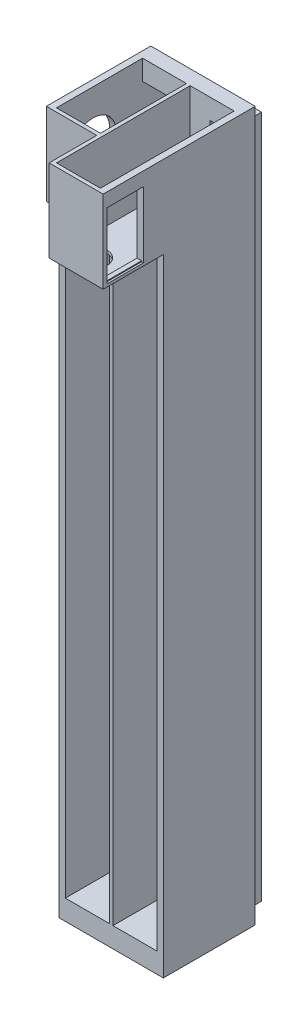
from build123d import *

# Parameters (mm, degrees)
SZKIC1_W                     = 53
SZKIC1_H                     = 374
SZKIC1_W_2                   = 24
SZKIC1_H_2                   = 365
DODANIE_WYCI_GNI_CIE2_DEPTH  = 12
SZKIC2_W                     = 12
SZKIC2_H                     = 3.5
WYTNIJ_WYCI_GNI_CIE1_DEPTH   = 2
SZKIC3_W                     = 53
SZKIC3_H                     = 374
DODANIE_WYCI_GNI_CIE3_DEPTH  = 2
SZKIC4_W                     = 13.3
SZKIC4_H                     = 30.500081729
SZKIC4_W_2                   = 9.4
SZKIC4_H_2                   = 64.96
WYTNIJ_WYCI_GNI_CIE2_DEPTH   = 2
SZKIC5_W                     = 2
SZKIC5_H                     = 374
DODANIE_WYCI_GNI_CIE4_DEPTH  = 43
DODANIE_WYCI_GNI_CIE5_DEPTH  = 41.5
SZKIC7_W                     = 25.5
SZKIC7_H                     = 38.500081729
DODANIE_WYCI_GNI_CIE6_DEPTH  = 1.5
DODANIE_WYCI_GNI_CIE7_DEPTH  = 43
DODANIE_WYCI_GNI_CIE8_DEPTH  = 43
SZKIC15_W                    = 57
SZKIC15_H                    = 374
DODANIE_WYCI_GNI_CIE10_DEPTH = 1
SZKIC16_W                    = 57
SZKIC16_H                    = 374
DODANIE_WYCI_GNI_CIE11_DEPTH = 1
SZKIC17_W                    = 55
SZKIC17_H                    = 57
SZKIC17_W_2                  = 24
SZKIC17_H_2                  = 41.5
DODANIE_WYCI_GNI_CIE12_DEPTH = 1
SZKIC18_W                    = 55
SZKIC18_H                    = 57
DODANIE_WYCI_GNI_CIE13_DEPTH = 1
SZKIC19_W                    = 55
SZKIC19_H                    = 376
SZKIC19_W_2                  = 52
SZKIC19_H_2                  = 373
WYTNIJ_WYCI_GNI_CIE7_DEPTH   = 6
SZKIC23_W                    = 24
SZKIC23_H                    = 38.000081729
WYTNIJ_WYCI_GNI_CIE11_DEPTH  = 10
DODANIE_WYCI_GNI_CIE14_DEPTH = 32
SZKIC25_W                    = 24
SZKIC25_H                    = 2
DODANIE_WYCI_GNI_CIE15_DEPTH = 38
SZKIC27_R                    = 7
WYTNIJ_WYCI_GNI_CIE12_DEPTH  = 10
SZKIC29_W                    = 20
SZKIC29_H                    = 35.5
WYTNIJ_WYCI_GNI_CIE13_DEPTH  = 3
DODANIE_WYCI_GNI_CIE16_DEPTH = 6
SZKIC31_W                    = 24
SZKIC31_H                    = 2
DODANIE_WYCI_GNI_CIE17_DEPTH = 38
SZKIC32_R                    = 12.5
WYTNIJ_WYCI_GNI_CIE14_DEPTH  = 3
SZKIC33_W                    = 24
SZKIC33_H                    = 73
SZKIC33_H_2                  = 47
DODANIE_WYCI_GNI_CIE18_DEPTH = 5.5
SZKIC34_W                    = 55
SZKIC34_H                    = 51
DODANIE_WYCI_GNI_CIE19_DEPTH = 5.5
SZKIC35_W                    = 20
SZKIC35_H                    = 36
DODANIE_WYCI_GNI_CIE20_DEPTH = 1
SZKIC36_R                    = 12.5
DODANIE_WYCI_GNI_CIE21_DEPTH = 1
SZKIC37_W                    = 57
SZKIC37_H                    = 341.999918271
WYTNIJ_WYCI_GNI_CIE15_DEPTH  = 0.85


with BuildPart() as part:
    # Szkic1 → Dodanie-wyciągnięcie2 (new body)
    with BuildSketch(Plane.XY):
        with Locations((-65.426891924, -133.239080048)):
            Rectangle(SZKIC1_W, SZKIC1_H)
        with Locations((-78.426891924, -133.239080048)):
            Rectangle(SZKIC1_W_2, SZKIC1_H_2, mode=Mode.SUBTRACT)
        with Locations((-52.426891924, -133.239080048)):
            Rectangle(SZKIC1_W_2, SZKIC1_H_2, mode=Mode.SUBTRACT)
    extrude(amount=DODANIE_WYCI_GNI_CIE2_DEPTH)

    # Szkic2 → Wytnij-wyciągnięcie1 (cut)
    with BuildSketch(Plane.ZY.offset(66.426891924)):
        with Locations((6, 47.510919952)):
            Rectangle(SZKIC2_W, SZKIC2_H)
    extrude(amount=-WYTNIJ_WYCI_GNI_CIE1_DEPTH, mode=Mode.SUBTRACT)

    # Szkic3 → Dodanie-wyciągnięcie3 (add)
    with BuildSketch(Plane.XY.offset(12)):
        with Locations((-65.426891924, -133.239080048)):
            Rectangle(SZKIC3_W, SZKIC3_H)
    extrude(amount=DODANIE_WYCI_GNI_CIE3_DEPTH)

    # Szkic4 → Wytnij-wyciągnięcie2 (cut)
    with BuildSketch(Plane.XY.offset(14)):
        Polygon((-46.926891924, -11.039080048), (-56.326891924, -11.039080048), (-56.326891924, -35.399080048), (-56.326891924, -40.479080048), (-46.926891924, -40.479080048), (-46.926891924, -35.399080048), align=None)
        with Locations((-47.076891924, 34.010879088)):
            Rectangle(SZKIC4_W, SZKIC4_H)
        with Locations((-83.776891924, 34.010879088)):
            Rectangle(SZKIC4_W, SZKIC4_H)
        Polygon((-74.526891924, -35.399080048), (-74.526891924, -40.479080048), (-83.926891924, -40.479080048), (-83.926891924, -35.399080048), (-83.926891924, -11.039080048), (-74.526891924, -11.039080048), align=None)
        with Locations((-51.626891924, -133.719080048)):
            Rectangle(SZKIC4_W_2, SZKIC4_H_2)
        with Locations((-79.226891924, -133.719080048)):
            Rectangle(SZKIC4_W_2, SZKIC4_H_2)
    extrude(amount=-WYTNIJ_WYCI_GNI_CIE2_DEPTH, mode=Mode.SUBTRACT)

    # Szkic5 → Dodanie-wyciągnięcie4 (add)
    with BuildSketch(Plane.XY.offset(14)):
        with Locations((-65.426891924, -133.239080048)):
            Rectangle(SZKIC5_W, SZKIC5_H)
    extrude(amount=DODANIE_WYCI_GNI_CIE4_DEPTH)

    # Szkic6 → Dodanie-wyciągnięcie5 (add)
    with BuildSketch(Plane.XY.offset(14)):
        Polygon((-64.426891924, 16.760838223), (-40.426891924, 16.760838223), (-40.426891924, 53.760919952), (-38.926891924, 53.760919952), (-38.926891924, 15.260838223), (-64.426891924, 15.260838223), align=None)
        Polygon((-90.426891924, 53.760919952), (-91.926891924, 53.760919952), (-91.926891924, 15.260838223), (-66.426891924, 15.260838223), (-66.426891924, 16.760838223), (-90.426891924, 16.760838223), align=None)
    extrude(amount=DODANIE_WYCI_GNI_CIE5_DEPTH)

    # Szkic7 → Dodanie-wyciągnięcie6 (add)
    with BuildSketch(Plane.XY.offset(55.5)):
        with Locations((-51.676891924, 34.510879088)):
            Rectangle(SZKIC7_W, SZKIC7_H)
        with Locations((-79.176891924, 34.510879088)):
            Rectangle(SZKIC7_W, SZKIC7_H)
    extrude(amount=DODANIE_WYCI_GNI_CIE6_DEPTH)

    # Szkic10 → Dodanie-wyciągnięcie7 (add)
    with BuildSketch(Plane.XY.offset(14)):
        Polygon((-91.926891924, 15.260838223), (-91.926891924, -320.239080048), (-66.426891924, -320.239080048), (-66.426891924, -315.739080048), (-90.426891924, -315.739080048), (-90.426891924, 15.260838223), align=None)
    extrude(amount=DODANIE_WYCI_GNI_CIE7_DEPTH)

    # Szkic11 → Dodanie-wyciągnięcie8 (add)
    with BuildSketch(Plane.XY.offset(14)):
        Polygon((-38.926891924, 15.260838223), (-38.926891924, -320.239080048), (-64.426891924, -320.239080048), (-64.426891924, -315.739080048), (-40.426891924, -315.739080048), (-40.426891924, 15.260838223), align=None)
    extrude(amount=DODANIE_WYCI_GNI_CIE8_DEPTH)

    # Szkic15 → Dodanie-wyciągnięcie10 (add)
    with BuildSketch(Plane.ZY.offset(91.926891924)):
        with Locations((28.5, -133.239080048)):
            Rectangle(SZKIC15_W, SZKIC15_H)
    extrude(amount=DODANIE_WYCI_GNI_CIE10_DEPTH)

    # Szkic16 → Dodanie-wyciągnięcie11 (add)
    with BuildSketch(Plane(origin=(-38.926891924, 0, 0), x_dir=(0, 0, -1), z_dir=(1, 0, 0))):
        with Locations((-28.5, -133.239080048)):
            Rectangle(SZKIC16_W, SZKIC16_H)
    extrude(amount=DODANIE_WYCI_GNI_CIE11_DEPTH)

    # Szkic17 → Dodanie-wyciągnięcie12 (add)
    with BuildSketch(Plane(origin=(0, 53.760919952, 0), x_dir=(1, 0, 0), z_dir=(0, 1, 0))):
        with Locations((-65.426891924, -28.5)):
            Rectangle(SZKIC17_W, SZKIC17_H)
        with Locations((-52.426891924, -34.75)):
            Rectangle(SZKIC17_W_2, SZKIC17_H_2, mode=Mode.SUBTRACT)
        with Locations((-78.426891924, -34.75)):
            Rectangle(SZKIC17_W_2, SZKIC17_H_2, mode=Mode.SUBTRACT)
    extrude(amount=DODANIE_WYCI_GNI_CIE12_DEPTH)

    # Szkic18 → Dodanie-wyciągnięcie13 (add)
    with BuildSketch(Plane.XZ.offset(320.239080048)):
        with Locations((-65.426891924, 28.5)):
            Rectangle(SZKIC18_W, SZKIC18_H)
    extrude(amount=DODANIE_WYCI_GNI_CIE13_DEPTH)

    # Szkic19 → Wytnij-wyciągnięcie7 (cut)
    with BuildSketch(Plane(origin=(0, 0, 0), x_dir=(-1, 0, 0), z_dir=(0, 0, -1))):
        with Locations((65.426891924, -133.239080048)):
            Rectangle(SZKIC19_W, SZKIC19_H)
        with Locations((65.426891924, -133.239080048)):
            Rectangle(SZKIC19_W_2, SZKIC19_H_2, mode=Mode.SUBTRACT)
    extrude(amount=-WYTNIJ_WYCI_GNI_CIE7_DEPTH, mode=Mode.SUBTRACT)

    # Szkic23 → Wytnij-wyciągnięcie11 (cut)
    with BuildSketch(Plane.XY.offset(57)):
        with Locations((-52.426891924, 35.760879088)):
            Rectangle(SZKIC23_W, SZKIC23_H)
        with Locations((-78.426891924, 35.760879088)):
            Rectangle(SZKIC23_W, SZKIC23_H)
    extrude(amount=-WYTNIJ_WYCI_GNI_CIE11_DEPTH, mode=Mode.SUBTRACT)

    # Szkic24 → Dodanie-wyciągnięcie14 (add)
    with BuildSketch(Plane.XY.offset(57)):
        Polygon((-40.426891924, 54.760919952), (-37.926891924, 54.760919952), (-37.926891924, 15.260838223), (-66.426891924, 15.260838223), (-66.426891924, 16.760838223), (-66.426891924, 54.760919952), (-64.426891924, 54.760919952), (-64.426891924, 16.760838223), (-40.426891924, 16.760838223), align=None)
    extrude(amount=DODANIE_WYCI_GNI_CIE14_DEPTH)

    # Szkic25 → Dodanie-wyciągnięcie15 (add)
    with BuildSketch(Plane(origin=(0, 16.760838223, 0), x_dir=(1, 0, 0), z_dir=(0, 1, 0))):
        with Locations((-52.426891924, -88)):
            Rectangle(SZKIC25_W, SZKIC25_H)
    extrude(amount=DODANIE_WYCI_GNI_CIE15_DEPTH)

    # Szkic27 → Wytnij-wyciągnięcie12 (cut)
    with BuildSketch(Plane.XZ.offset(-15.260838223)):
        with Locations((-52.676891924, 78)):
            Circle(SZKIC27_R)
    extrude(amount=-WYTNIJ_WYCI_GNI_CIE12_DEPTH, mode=Mode.SUBTRACT)

    # Szkic29 → Wytnij-wyciągnięcie13 (cut)
    with BuildSketch(Plane(origin=(-37.926891924, 0, 0), x_dir=(0, 0, -1), z_dir=(1, 0, 0))):
        with Locations((-77, 35.010838223)):
            Rectangle(SZKIC29_W, SZKIC29_H)
    extrude(amount=-WYTNIJ_WYCI_GNI_CIE13_DEPTH, mode=Mode.SUBTRACT)

    # Szkic30 → Dodanie-wyciągnięcie16 (add)
    with BuildSketch(Plane.XY.offset(57)):
        Polygon((-66.426891924, 16.760838223), (-66.426891924, 15.260838223), (-92.926891924, 15.260838223), (-92.926891924, 54.760919952), (-90.426891924, 54.760919952), (-90.426891924, 16.760838223), align=None)
    extrude(amount=DODANIE_WYCI_GNI_CIE16_DEPTH)

    # Szkic31 → Dodanie-wyciągnięcie17 (add)
    with BuildSketch(Plane(origin=(0, 16.760838223, 0), x_dir=(1, 0, 0), z_dir=(0, 1, 0))):
        with Locations((-78.426891924, -62)):
            Rectangle(SZKIC31_W, SZKIC31_H)
    extrude(amount=DODANIE_WYCI_GNI_CIE17_DEPTH)

    # Szkic32 → Wytnij-wyciągnięcie14 (cut)
    with BuildSketch(Plane.ZY.offset(92.926891924)):
        with Locations((41, 33.010879088)):
            Circle(SZKIC32_R)
    extrude(amount=-WYTNIJ_WYCI_GNI_CIE14_DEPTH, mode=Mode.SUBTRACT)

    # Szkic33 → Dodanie-wyciągnięcie18 (add)
    with BuildSketch(Plane(origin=(0, 54.760919952, 0), x_dir=(1, 0, 0), z_dir=(0, 1, 0))):
        Polygon((-37.926891924, -89), (-66.426891924, -89), (-66.426891924, -63), (-92.926891924, -63), (-92.926891924, -6), (-37.926891924, -6), align=None)
        with Locations((-52.426891924, -50.5)):
            Rectangle(SZKIC33_W, SZKIC33_H, mode=Mode.SUBTRACT)
        with Locations((-78.426891924, -37.5)):
            Rectangle(SZKIC33_W, SZKIC33_H_2, mode=Mode.SUBTRACT)
    extrude(amount=DODANIE_WYCI_GNI_CIE18_DEPTH)

    # Szkic34 → Dodanie-wyciągnięcie19 (add)
    with BuildSketch(Plane.XZ.offset(321.239080048)):
        with Locations((-65.426891924, 31.5)):
            Rectangle(SZKIC34_W, SZKIC34_H)
    extrude(amount=DODANIE_WYCI_GNI_CIE19_DEPTH)

    # Szkic35 → Dodanie-wyciągnięcie20 (add)
    with BuildSketch(Plane(origin=(-37.926891924, 0, 0), x_dir=(0, 0, -1), z_dir=(1, 0, 0))):
        Polygon((-57, -326.739080048), (-57, 15.260838223), (-89, 15.260838223), (-89, 60.260919952), (-6, 60.260919952), (-6, -326.739080048), align=None)
        with Locations((-77, 34.760838223)):
            Rectangle(SZKIC35_W, SZKIC35_H, mode=Mode.SUBTRACT)
    extrude(amount=DODANIE_WYCI_GNI_CIE20_DEPTH)

    # Szkic36 → Dodanie-wyciągnięcie21 (add)
    with BuildSketch(Plane.ZY.offset(92.926891924)):
        Polygon((63, 60.260919952), (63, 15.260838223), (57, 15.260838223), (57, -326.739080048), (6, -326.739080048), (6, 60.260919952), align=None)
        with Locations((41, 33.010879088)):
            Circle(SZKIC36_R, mode=Mode.SUBTRACT)
    extrude(amount=DODANIE_WYCI_GNI_CIE21_DEPTH)

    # Szkic37 → Wytnij-wyciągnięcie15 (cut)
    with BuildSketch(Plane.XY.offset(57)):
        with Locations((-65.426891924, -155.739120912)):
            Rectangle(SZKIC37_W, SZKIC37_H)
    extrude(amount=-WYTNIJ_WYCI_GNI_CIE15_DEPTH, mode=Mode.SUBTRACT)


solid = part.part
